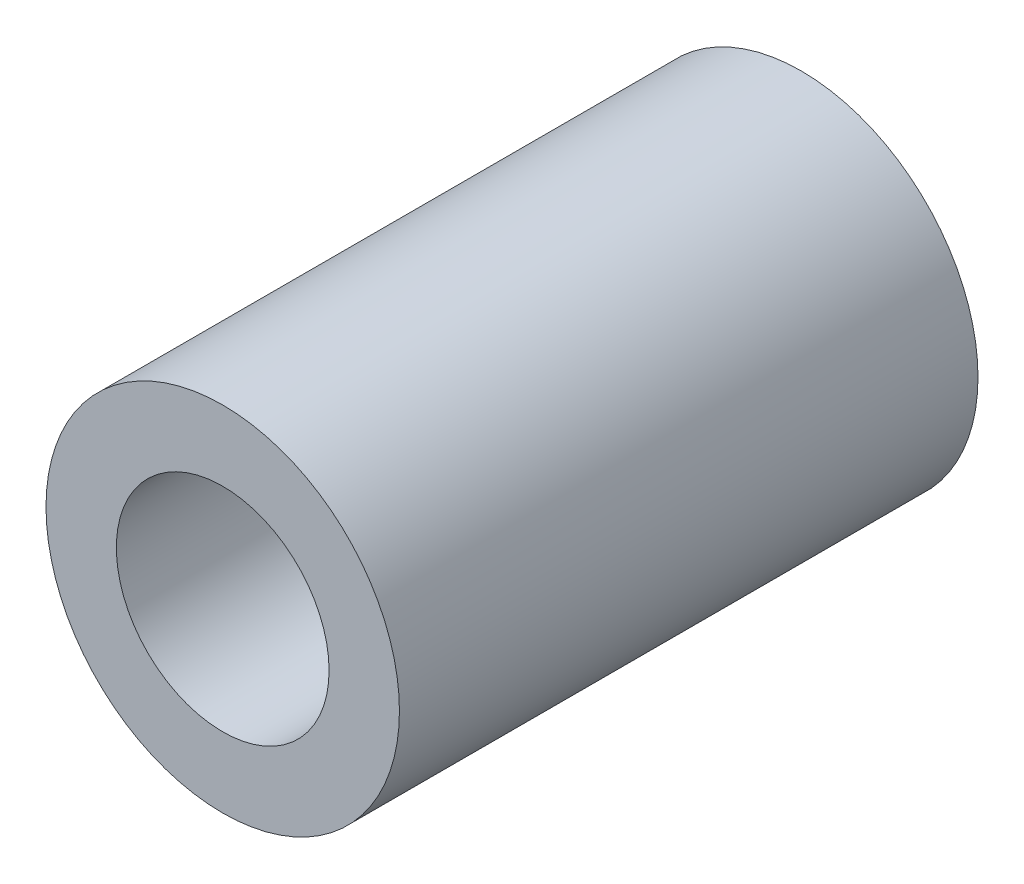
from build123d import *

# Parameters (mm, degrees)
SKETCH1_R           = 7.9756
SKETCH1_R_2         = 4.8006
BOSS_EXTRUDE1_DEPTH = 26.1112


with BuildPart() as part:
    # Sketch1 → Boss-Extrude1 (new body)
    with BuildSketch(Plane.XY):
        Circle(SKETCH1_R)
        Circle(SKETCH1_R_2, mode=Mode.SUBTRACT)
    extrude(amount=BOSS_EXTRUDE1_DEPTH)


solid = part.part
